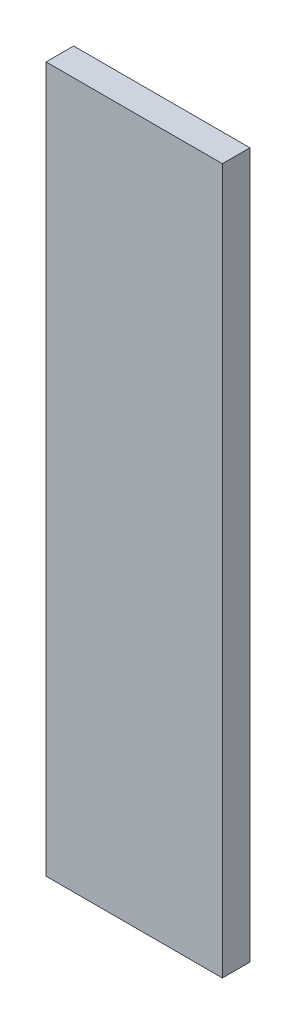
from build123d import *

# Parameters (mm, degrees)
SKETCH1_W           = 76.2
SKETCH1_H           = 304.8
BOSS_EXTRUDE1_DEPTH = 11.90625


with BuildPart() as part:
    # Sketch1 → Boss-Extrude1 (new body)
    with BuildSketch(Plane.XY):
        with Locations((0, 257.175230505)):
            Rectangle(SKETCH1_W, SKETCH1_H)
    extrude(amount=-BOSS_EXTRUDE1_DEPTH)


solid = part.part
